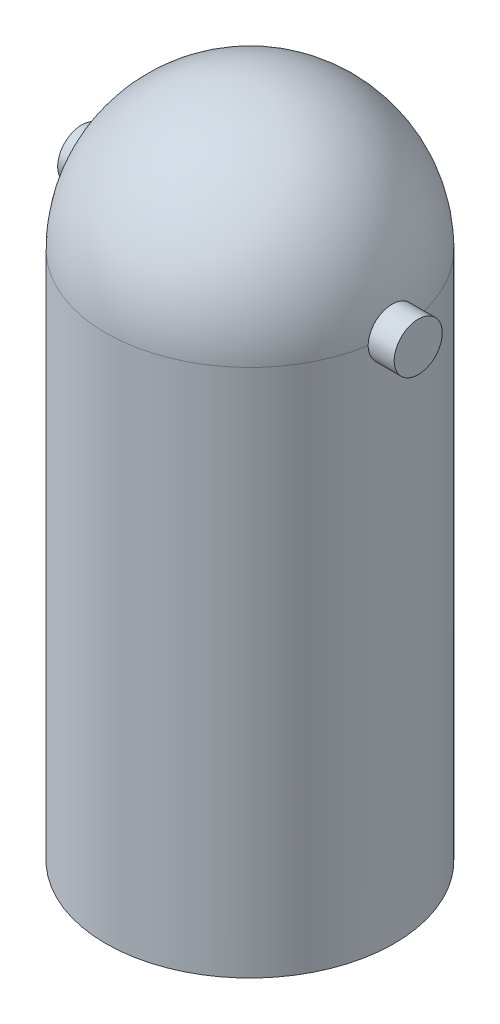
from build123d import *

# Parameters (mm, degrees)
SKETCH1_R           = 30
BOSS_EXTRUDE1_DEPTH = 110
SKETCH6_R           = 20
CUT_EXTRUDE2_DEPTH  = 100
SKETCH7_R           = 5
BOSS_EXTRUDE2_DEPTH = 35


with BuildPart() as part:
    # Sketch1 → Boss-Extrude1 (new body)
    with BuildSketch(Plane(origin=(0, 0, 0), x_dir=(1, 0, 0), z_dir=(0, 1, 0))):
        Circle(SKETCH1_R)
    extrude(amount=BOSS_EXTRUDE1_DEPTH)

    # Sketch5 → Revolve1 (revolve)
    with BuildSketch(Plane.XY):
        with BuildLine():
            Line((-30, 110), (0, 110))
            Line((0, 110), (30, 110))
            ThreePointArc((30, 110), (0, 140), (-30, 110))
        make_face()
    revolve(axis=Axis((-30, 110, 0), (1, 0, 0)))

    # Sketch6 → Cut-Extrude2 (cut)
    with BuildSketch(Plane.XZ):
        Circle(SKETCH6_R)
    extrude(amount=-CUT_EXTRUDE2_DEPTH, mode=Mode.SUBTRACT)

    # Sketch7 → Boss-Extrude2 (add)
    with BuildSketch(Plane(origin=(0, 0, 0), x_dir=(0, 0, -1), z_dir=(1, 0, 0))):
        with Locations((0, 110)):
            Circle(SKETCH7_R)
    boss_extrude2 = extrude(amount=BOSS_EXTRUDE2_DEPTH)

    # Mirror1: Boss-Extrude2 across plane
    add(boss_extrude2.mirror(Plane(origin=(0, 0, 0), x_dir=(0, 0, 1), z_dir=(1, 0, 0))))


solid = part.part
